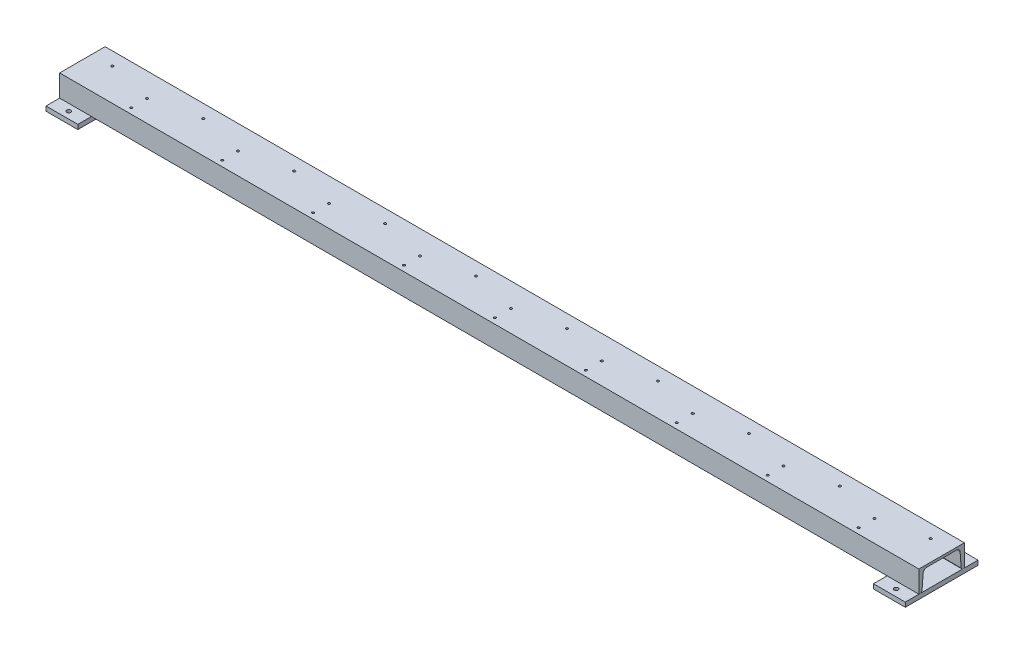
from build123d import *

# Parameters (mm, degrees)
MEMBER_10_1_DEPTH              = 1890
HOLE_WIZARD_M6_1_D             = 5
PATTERN_LINEAR_2_COUNT         = 9
PATTERN_LINEAR_2_PITCH         = 200
SKETCH_10_W                    = 70
SKETCH_10_H                    = 160
EXTRUDE_1_DEPTH                = 10
SKETCH_13_W                    = 4.5
SKETCH_13_H                    = 10
HOLE_WIZARD_9_0_9_1_AT_2_COUNT = 2
HOLE_WIZARD_9_0_9_1_AT_2_PITCH = 130
SKETCH_15_W                    = 2.5
SKETCH_15_H                    = 5.301
PATTERN_LINEAR_3_COUNT         = 10
PATTERN_LINEAR_3_PITCH         = 200


with BuildPart() as part:
    # Sketch1 → Member 10_1 (new body)
    with BuildSketch(Plane.YZ.offset(-945)):
        with BuildLine():
            Line((0, 0), (0, -100))
            Line((0, -100), (-48, -100))
            Line((-48, -100), (-48, -97.265512699))
            ThreePointArc((-48, -97.265512699), (-46.867155397, -94.376595562), (-44.072544834, -93.027769806))
            Line((-44.072544834, -93.027769806), (-13.154910332, -90.674554065))
            ThreePointArc((-13.154910332, -90.674554065), (-7.565689205, -87.976902554), (-5.3, -82.199068278))
            Line((-5.3, -82.199068278), (-5.3, -17.800931722))
            ThreePointArc((-5.3, -17.800931722), (-7.565689205, -12.023097446), (-13.154910332, -9.325445935))
            Line((-13.154910332, -9.325445935), (-44.072544834, -6.972230194))
            ThreePointArc((-44.072544834, -6.972230194), (-46.867155397, -5.623404438), (-48, -2.734487301))
            Line((-48, -2.734487301), (-48, 0))
            Line((-48, 0), (0, 0))
        make_face()
    extrude(amount=MEMBER_10_1_DEPTH)

    # M6 螺纹孔1 (through all)
    with Locations(Plane(origin=(-800, 0, -12.5), x_dir=(0, 0, 1), z_dir=(0, 1, 0))):
        with Locations((0, 0), (-35, 0)):
            hole_wizard_m6_1 = Hole(HOLE_WIZARD_M6_1_D / 2)

    # 阵列(线性)2: M6 螺纹孔1 ×9
    with Locations(*[(i * PATTERN_LINEAR_2_PITCH, 0, 0) for i in range(1, PATTERN_LINEAR_2_COUNT)]):
        add(hole_wizard_m6_1, mode=Mode.SUBTRACT)

    # 草图15 → M6 螺纹孔2 (revolve, cut)
    with BuildSketch(Plane(origin=(900, 0, -71), x_dir=(0, 0, 1), z_dir=(1, 0, 0))):
        with Locations((1.25, 2.6505)):
            Rectangle(SKETCH_15_W, SKETCH_15_H)
    hole_wizard_m6_2 = revolve(axis=Axis((900, 6.35, -71), (0, -1, 0)), mode=Mode.SUBTRACT)

    # 阵列(线性)3: M6 螺纹孔2 ×10
    with Locations(*[(-i * PATTERN_LINEAR_3_PITCH, 0, 0) for i in range(1, PATTERN_LINEAR_3_COUNT)]):
        add(hole_wizard_m6_2, mode=Mode.SUBTRACT)


with BuildPart() as body_2:
    # 草图10 → 凸台-拉伸1 (new body)
    with BuildSketch(Plane.XZ.offset(48)):
        with Locations((-910, -50)):
            Rectangle(SKETCH_10_W, SKETCH_10_H)
    extrude(amount=EXTRUDE_1_DEPTH)

    # 草图13 → Ø9.0 (9) 直径孔1 (revolve, cut)
    with BuildSketch(Plane(origin=(-910, -48, -115), x_dir=(0, 0, 1), z_dir=(1, 0, 0))):
        with Locations((2.25, 5)):
            Rectangle(SKETCH_13_W, SKETCH_13_H)
    hole_wizard_9_0_9_1 = revolve(axis=Axis((-910, -41.65, -115), (0, -1, 0)), mode=Mode.SUBTRACT)

    # Ø9.0 (9) 直径孔1 at 2: Ø9.0 (9) 直径孔1 ×2
    with Locations(*[(0, 0, i * HOLE_WIZARD_9_0_9_1_AT_2_PITCH) for i in range(1, HOLE_WIZARD_9_0_9_1_AT_2_COUNT)]):
        add(hole_wizard_9_0_9_1, mode=Mode.SUBTRACT)


with BuildPart() as body_3:
    # 镜向1: mirrored copy
    add(body_2.part.mirror(Plane(origin=(0, 0, 0), x_dir=(0, 0, 1), z_dir=(1, 0, 0))))


solid = Compound([part.part, body_2.part, body_3.part])
